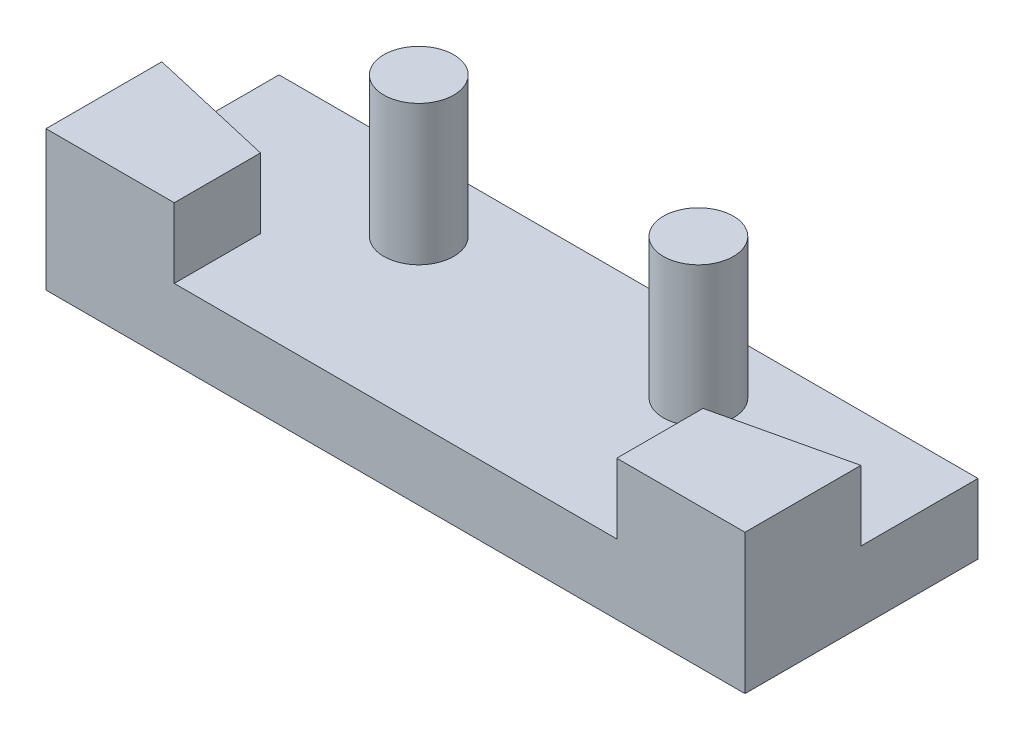
from build123d import *

# Parameters (mm, degrees)
SKETCH2_W             = 30
SKETCH2_H             = 10
BOSS_EXTRUDE2_DEPTH   = 6
CUT_EXTRUDE1_DEPTH    = 3
SKETCH4_4_R           = 1.5
BOSS_EXTRUDE4_DEPTH   = 3
BOSS_EXTRUDE4_2_DEPTH = 3
SKETCH4_5_R           = 1.5
BOSS_EXTRUDE5_DEPTH   = 3


with BuildPart() as part:
    # Sketch2 → Boss-Extrude2 (new body)
    with BuildSketch(Plane(origin=(0, 0, 0), x_dir=(1, 0, 0), z_dir=(0, 1, 0))):
        with Locations((15, -5)):
            Rectangle(SKETCH2_W, SKETCH2_H)
    extrude(amount=BOSS_EXTRUDE2_DEPTH)

    # Sketch4 → Cut-Extrude1 (cut)
    with BuildSketch(Plane(origin=(0, 6, 0), x_dir=(1, 0, 0), z_dir=(0, 1, 0))):
        Polygon((0, -5.027402711), (5.504275855, -6.298164921), (5.504275855, -10), (24.495724145, -10), (24.495724145, -6.298164921), (30, -5.027402711), (30, 0), (0, 0), align=None)
    extrude(amount=-CUT_EXTRUDE1_DEPTH, mode=Mode.SUBTRACT)



with BuildPart() as body_2:
    # Sketch4_4 → Boss-Extrude4 (new body)
    with BuildSketch(Plane(origin=(0, 6, 0), x_dir=(1, 0, 0), z_dir=(0, 1, 0))):
        with Locations((9, -3)):
            Circle(SKETCH4_4_R)
    extrude(amount=BOSS_EXTRUDE4_DEPTH)


with BuildPart() as body_3:
    # Sketch4_4 → Boss-Extrude4 2 (new body)
    with BuildSketch(Plane(origin=(0, 6, 0), x_dir=(1, 0, 0), z_dir=(0, 1, 0))):
        with Locations((21, -3)):
            Circle(SKETCH4_4_R)
    extrude(amount=BOSS_EXTRUDE4_2_DEPTH)


with BuildPart() as part_1:
    add(part.part)

    add(body_2.part)  # Boss-Extrude5 merges body 2

    add(body_3.part)  # Boss-Extrude5 merges body 3
    # Sketch4_5 → Boss-Extrude5 (add)
    with BuildSketch(Plane(origin=(0, 6, 0), x_dir=(1, 0, 0), z_dir=(0, 1, 0))):
        with Locations((9, -3)):
            Circle(SKETCH4_5_R)
        with Locations((21, -3)):
            Circle(SKETCH4_5_R)
    extrude(amount=-BOSS_EXTRUDE5_DEPTH)


solid = part_1.part
